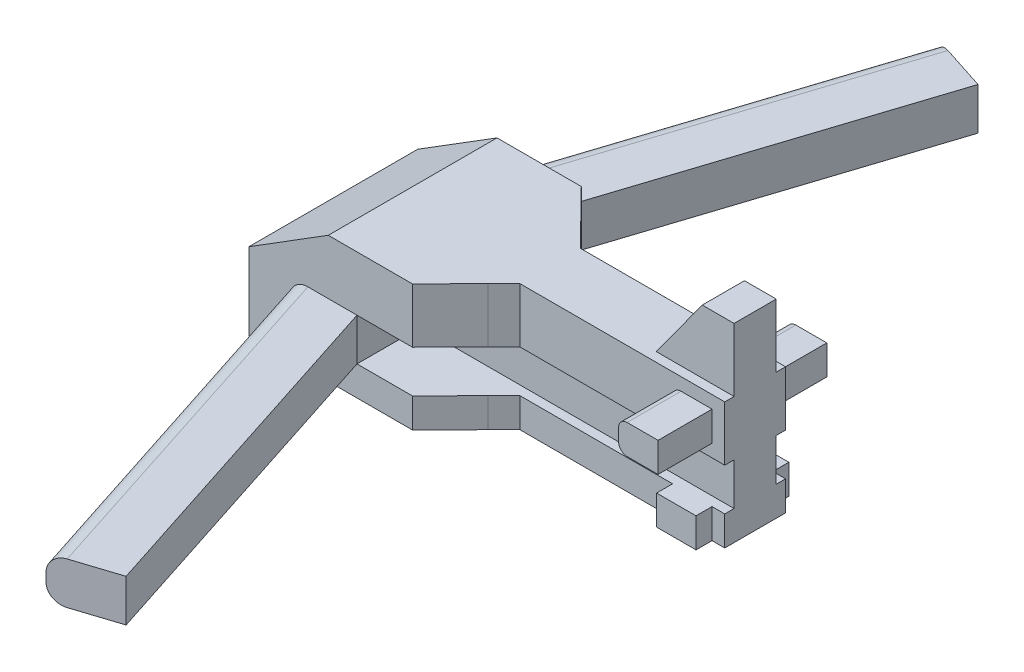
from build123d import *

# Parameters (mm, degrees)
BOSS_EXTRUDE1_DEPTH = 101.6
BOSS_EXTRUDE2_START = -33.02
BOSS_EXTRUDE2_DEPTH = 25.4
SKETCH4_W           = 195.058436962
SKETCH4_H           = 25.4
CUT_EXTRUDE1_DEPTH  = 38.1
SKETCH5_W           = 191.898505545
SKETCH5_H           = 25.4
CUT_EXTRUDE4_DEPTH  = 38.1
CUT_EXTRUDE5_DEPTH  = 101.6
BOSS_EXTRUDE3_START = -63.5
BOSS_EXTRUDE3_DEPTH = 25.4
FILLET1_R           = 10.16
FILLET2_R           = 10.16
FILLET3_R           = 10.16
FILLET4_R           = 10.16
SKETCH9_W           = 22.86
SKETCH9_H           = 17.78
CUT_EXTRUDE6_DEPTH  = 50.8
SKETCH10_W          = 7.656009699
SKETCH10_H          = 32.499666645
CUT_EXTRUDE7_DEPTH  = 77.2
CUT_EXTRUDE8_DEPTH  = 77.2
SKETCH12_W          = 32.499666645
SKETCH12_H          = 7.62
CUT_EXTRUDE9_DEPTH  = 50.8
FILLET6_R           = 5.08


with BuildPart() as part:
    # Sketch1 → Boss-Extrude1 (new body)
    with BuildSketch(Plane.XY):
        Polygon((0, 0), (-69.85, 0), (-69.85, 46.373441022), (-22.065879406, 76.2), (184.15, 76.2), (184.15, 0), align=None)
    extrude(amount=-BOSS_EXTRUDE1_DEPTH)

    # Sketch3 → Boss-Extrude2 (add)
    with BuildSketch(Plane(origin=(0, 76.2, 0), x_dir=(1, 0, 0), z_dir=(0, 1, 0)).offset(BOSS_EXTRUDE2_START)):
        Polygon((-45.019314853, 101.6), (25.443042364, 319.069575379), (61.864542757, 307.268638321), (-4.774190667, 101.6), align=None)
        Polygon((-4.774190667, 0), (-45.019314853, 0), (25.443042364, -217.469575379), (61.864542757, -205.668638321), align=None)
    extrude(amount=-BOSS_EXTRUDE2_DEPTH)

    # Sketch4 → Cut-Extrude1 (cut)
    with BuildSketch(Plane.XY):
        with Locations((92.755027814, 30.48)):
            Rectangle(SKETCH4_W, SKETCH4_H)
    extrude(amount=-CUT_EXTRUDE1_DEPTH, mode=Mode.SUBTRACT)

    # Sketch5 → Cut-Extrude4 (cut)
    with BuildSketch(Plane(origin=(0, 0, -101.6), x_dir=(-1, 0, 0), z_dir=(0, 0, -1))):
        with Locations((-91.175062106, 30.48)):
            Rectangle(SKETCH5_W, SKETCH5_H)
    extrude(amount=-CUT_EXTRUDE4_DEPTH, mode=Mode.SUBTRACT)

    # Sketch6 → Cut-Extrude5 (cut)
    with BuildSketch(Plane(origin=(0, 76.2, 0), x_dir=(1, 0, 0), z_dir=(0, 1, 0))):
        Polygon((28.659266364, 0), (51.128382236, 22.86), (152.752463445, 22.86), (152.752463445, 0), align=None)
        Polygon((152.752463445, 78.74), (152.752463445, 101.6), (28.659266364, 101.6), (51.128382236, 78.74), align=None)
    extrude(amount=-CUT_EXTRUDE5_DEPTH, mode=Mode.SUBTRACT)

    # Sketch8 → Boss-Extrude3 (add)
    with BuildSketch(Plane.XY.offset(BOSS_EXTRUDE3_START)):
        Polygon((184.15, 76.2), (184.15, 114.315616278), (165.003698403, 114.315616278), (137.329725858, 76.2), align=None)
    extrude(amount=BOSS_EXTRUDE3_DEPTH)

    # Fillet1
    fillet1_edges = [part.edges().sort_by_distance(p)[0] for p in [
        (-9.788136245, 43.18, 108.734787689),
    ]]
    fillet(fillet1_edges, radius=FILLET1_R)

    # Fillet2
    fillet2_edges = [part.edges().sort_by_distance(p)[0] for p in [
        (-9.788136245, 17.78, 108.734787689),
    ]]
    fillet(fillet2_edges, radius=FILLET2_R)

    # Fillet3
    fillet3_edges = [part.edges().sort_by_distance(p)[0] for p in [
        (-9.788136245, 43.18, -210.334787689),
    ]]
    fillet(fillet3_edges, radius=FILLET3_R)

    # Fillet4
    fillet4_edges = [part.edges().sort_by_distance(p)[0] for p in [
        (-9.788136245, 17.78, -210.334787689),
    ]]
    fillet(fillet4_edges, radius=FILLET4_R)

    # Sketch9 → Cut-Extrude6 (cut)
    with BuildSketch(Plane(origin=(184.15, 0, 0), x_dir=(0, 0, -1), z_dir=(1, 0, 0))):
        with Locations((90.17, 8.89)):
            Rectangle(SKETCH9_W, SKETCH9_H)
        with Locations((11.43, 8.89)):
            Rectangle(SKETCH9_W, SKETCH9_H)
    extrude(amount=-CUT_EXTRUDE6_DEPTH, mode=Mode.SUBTRACT)

    # Sketch10 → Cut-Extrude7 (cut, through all)
    with BuildSketch(Plane(origin=(0, 76.2, 0), x_dir=(1, 0, 0), z_dir=(0, 1, 0))):
        with Locations((180.321995151, 16.249833323)):
            Rectangle(SKETCH10_W, SKETCH10_H)
        with Locations((180.321995151, 85.350166677)):
            Rectangle(SKETCH10_W, SKETCH10_H)
    extrude(amount=-CUT_EXTRUDE7_DEPTH, mode=Mode.SUBTRACT)

    # Sketch11 → Cut-Extrude8 (cut, through all)
    with BuildSketch(Plane(origin=(0, 76.2, 0), x_dir=(1, 0, 0), z_dir=(0, 1, 0))):
        Polygon((152.752463445, 22.86), (152.752463445, 32.499666645), (60.768048881, 32.499666645), (51.128382236, 22.86), align=None)
        Polygon((152.752463445, 78.74), (152.752463445, 69.100333355), (60.768048881, 69.100333355), (51.128382236, 78.74), align=None)
    extrude(amount=-CUT_EXTRUDE8_DEPTH, mode=Mode.SUBTRACT)

    # Sketch12 → Cut-Extrude9 (cut)
    with BuildSketch(Plane(origin=(176.493990301, 0, 0), x_dir=(0, 0, -1), z_dir=(1, 0, 0))):
        with Locations((85.350166677, 72.39)):
            Rectangle(SKETCH12_W, SKETCH12_H)
        with Locations((85.350166677, 46.99)):
            Rectangle(SKETCH12_W, SKETCH12_H)
        with Locations((16.249833323, 46.99)):
            Rectangle(SKETCH12_W, SKETCH12_H)
        with Locations((16.249833323, 72.39)):
            Rectangle(SKETCH12_W, SKETCH12_H)
    extrude(amount=-CUT_EXTRUDE9_DEPTH, mode=Mode.SUBTRACT)

    # Fillet6
    fillet6_edges = [part.edges().sort_by_distance(p)[0] for p in [
        (152.752463445, 68.58, -16.249833323),
        (152.752463445, 50.8, -16.249833323),
        (152.752463445, 50.8, -85.350166677),
        (152.752463445, 68.58, -85.350166677),
    ]]
    fillet(fillet6_edges, radius=FILLET6_R)


solid = part.part
